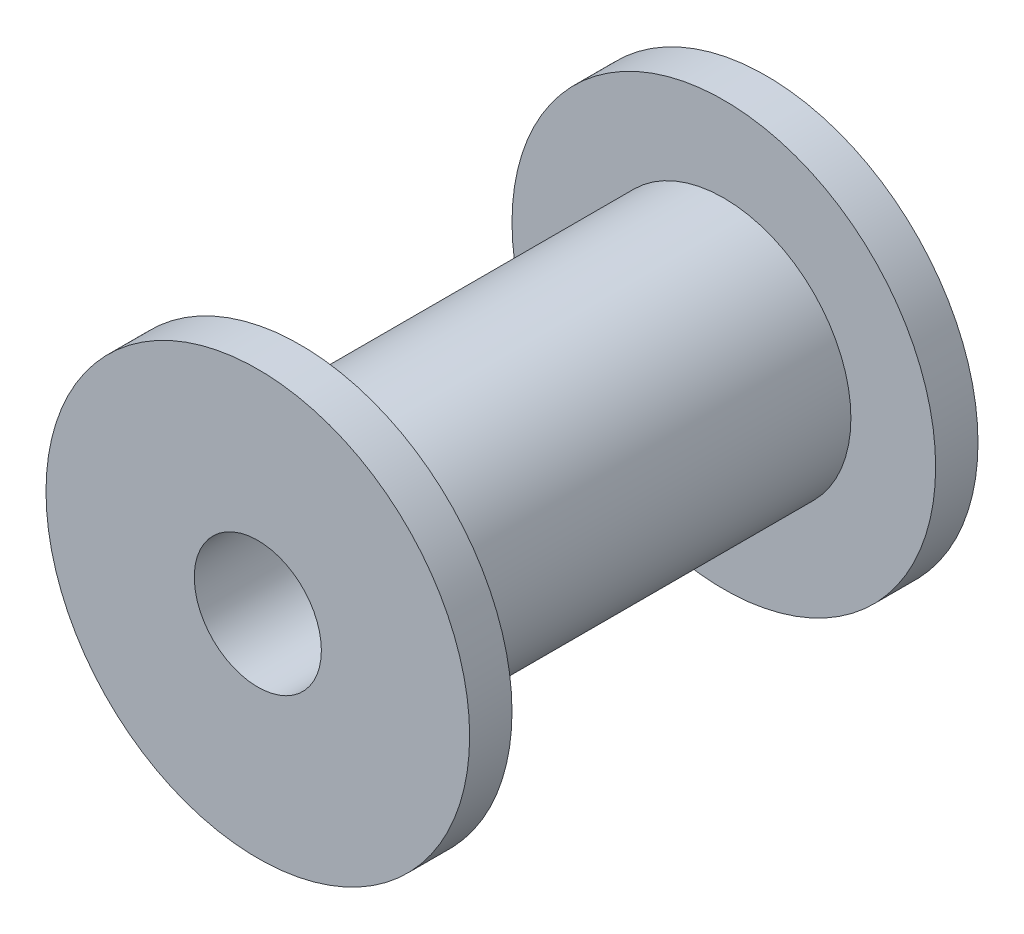
from build123d import *

# Parameters (mm, degrees)
SKETCH1_R           = 9.525
SKETCH1_R_2         = 4.7625
BOSS_EXTRUDE1_DEPTH = 15.875
BOSS_EXTRUDE2_START = 15.875
SKETCH1_3_R         = 15.875
SKETCH1_3_R_2       = 4.7625
BOSS_EXTRUDE2_DEPTH = 3.175


with BuildPart() as part:
    # Sketch1 → Boss-Extrude1 (new body)
    with BuildSketch(Plane.XY):
        Circle(SKETCH1_R)
        Circle(SKETCH1_R_2, mode=Mode.SUBTRACT)
    extrude(amount=BOSS_EXTRUDE1_DEPTH)

    # Sketch1_3 → Boss-Extrude2 (add)
    with BuildSketch(Plane.XY.offset(BOSS_EXTRUDE2_START)):
        Circle(SKETCH1_3_R)
        Circle(SKETCH1_3_R_2, mode=Mode.SUBTRACT)
    extrude(amount=BOSS_EXTRUDE2_DEPTH)

    # Mirror1: part across plane


with BuildPart() as part_1:
    add(part.part)
    add(part.part.mirror(Plane.XY))


solid = part_1.part
